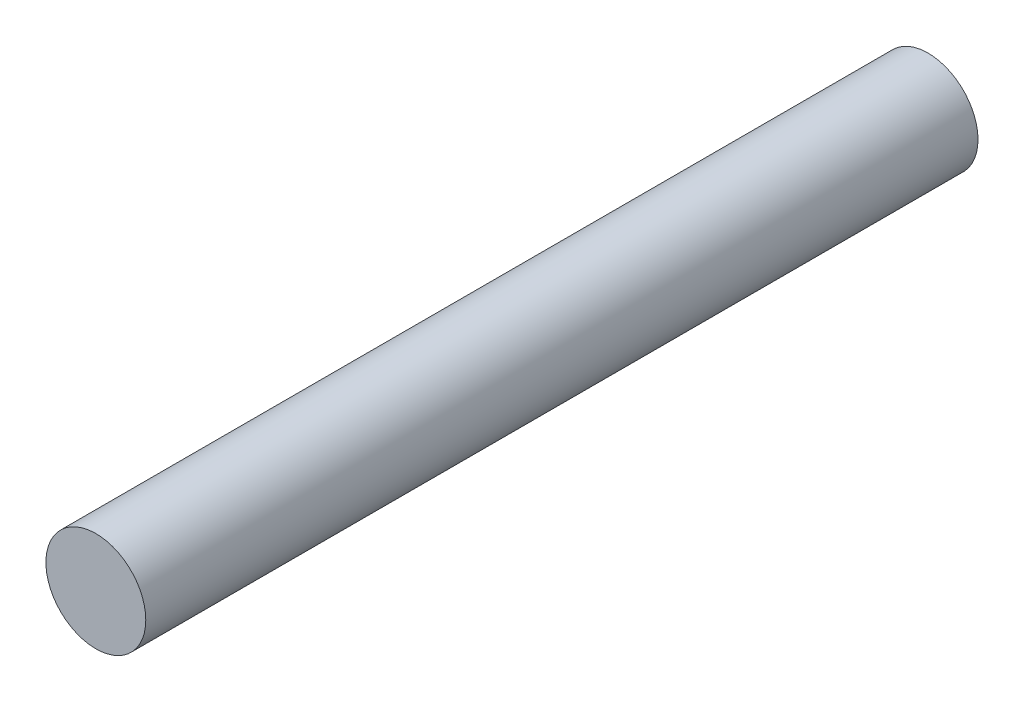
from build123d import *

# Parameters (mm, degrees)
SKETCH1_R           = 1.5
BOSS_EXTRUDE1_DEPTH = 25


with BuildPart() as part:
    # Sketch1 → Boss-Extrude1 (new body)
    with BuildSketch(Plane.XY):
        Circle(SKETCH1_R)
    extrude(amount=BOSS_EXTRUDE1_DEPTH)


solid = part.part
